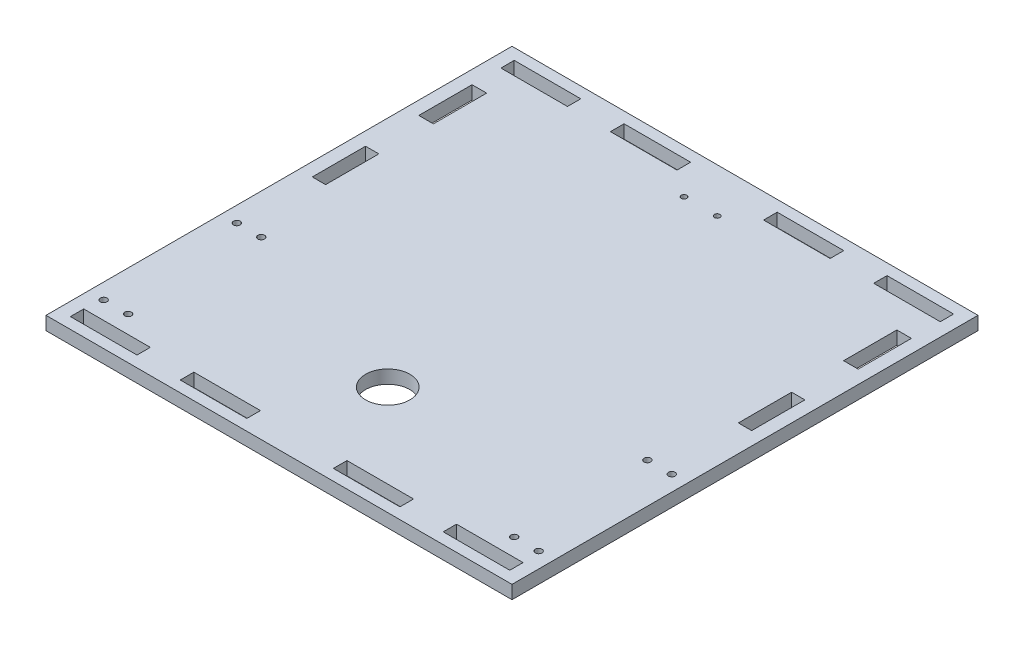
from build123d import *

# Parameters (mm, degrees)
SKETCH1_W           = 210
SKETCH1_H           = 210
SKETCH1_R           = 1.5
SKETCH1_R_2         = 10
SKETCH1_R_3         = 1.25
SKETCH1_W_2         = 30
SKETCH1_H_2         = 6.134133664
SKETCH1_H_3         = 6
SKETCH1_W_3         = 6.572229622
SKETCH1_H_4         = 24
SKETCH1_W_4         = 6
BOSS_EXTRUDE1_DEPTH = 6


with BuildPart() as part:
    # Sketch1 → Boss-Extrude1 (new body)
    with BuildSketch(Plane(origin=(0, 0, 0), x_dir=(1, 0, 0), z_dir=(0, 1, 0))):
        with Locations((-0.850910849, -4.383508225)):
            Rectangle(SKETCH1_W, SKETCH1_H)
        with Locations((-98.850910849, -90.383508225)):
            Circle(SKETCH1_R, mode=Mode.SUBTRACT)
        with Locations((-87.850910849, -90.383508225)):
            Circle(SKETCH1_R, mode=Mode.SUBTRACT)
        with Locations((-0.850910849, -60.383508225)):
            Circle(SKETCH1_R_2, mode=Mode.SUBTRACT)
        with Locations((-87.850910849, -30.383508225)):
            Circle(SKETCH1_R, mode=Mode.SUBTRACT)
        with Locations((-98.850910849, -30.383508225)):
            Circle(SKETCH1_R, mode=Mode.SUBTRACT)
        with Locations((97.149089151, -90.383508225)):
            Circle(SKETCH1_R, mode=Mode.SUBTRACT)
        with Locations((86.149089151, -90.383508225)):
            Circle(SKETCH1_R, mode=Mode.SUBTRACT)
        with Locations((86.149089151, -30.383508225)):
            Circle(SKETCH1_R, mode=Mode.SUBTRACT)
        with Locations((97.149089151, -30.383508225)):
            Circle(SKETCH1_R, mode=Mode.SUBTRACT)
        with Locations((-8.324910849, 80.616491775)):
            Circle(SKETCH1_R_3, mode=Mode.SUBTRACT)
        with Locations((6.623089151, 80.616491775)):
            Circle(SKETCH1_R_3, mode=Mode.SUBTRACT)
        with Locations((-35.350910849, 92.549424943)):
            Rectangle(SKETCH1_W_2, SKETCH1_H_2, mode=Mode.SUBTRACT)
        with Locations((-84.850910849, 92.616491775)):
            Rectangle(SKETCH1_W_2, SKETCH1_H_3, mode=Mode.SUBTRACT)
        with Locations((33.649089151, 92.549424943)):
            Rectangle(SKETCH1_W_2, SKETCH1_H_2, mode=Mode.SUBTRACT)
        with Locations((83.149089151, 92.616491775)):
            Rectangle(SKETCH1_W_2, SKETCH1_H_3, mode=Mode.SUBTRACT)
        with Locations((83.149089151, -101.383508225)):
            Rectangle(SKETCH1_W_2, SKETCH1_H_3, mode=Mode.SUBTRACT)
        with Locations((33.649089151, -101.316441393)):
            Rectangle(SKETCH1_W_2, SKETCH1_H_2, mode=Mode.SUBTRACT)
        with Locations((-35.350910849, -101.316441393)):
            Rectangle(SKETCH1_W_2, SKETCH1_H_2, mode=Mode.SUBTRACT)
        with Locations((-84.850910849, -101.383508225)):
            Rectangle(SKETCH1_W_2, SKETCH1_H_3, mode=Mode.SUBTRACT)
        with Locations((-96.564796038, 64.616491775)):
            Rectangle(SKETCH1_W_3, SKETCH1_H_4, mode=Mode.SUBTRACT)
        with Locations((-96.850910849, 16.616491775)):
            Rectangle(SKETCH1_W_4, SKETCH1_H_4, mode=Mode.SUBTRACT)
        with Locations((95.149089151, 16.616491775)):
            Rectangle(SKETCH1_W_4, SKETCH1_H_4, mode=Mode.SUBTRACT)
        with Locations((94.86297434, 64.616491775)):
            Rectangle(SKETCH1_W_3, SKETCH1_H_4, mode=Mode.SUBTRACT)
    extrude(amount=BOSS_EXTRUDE1_DEPTH)


solid = part.part
